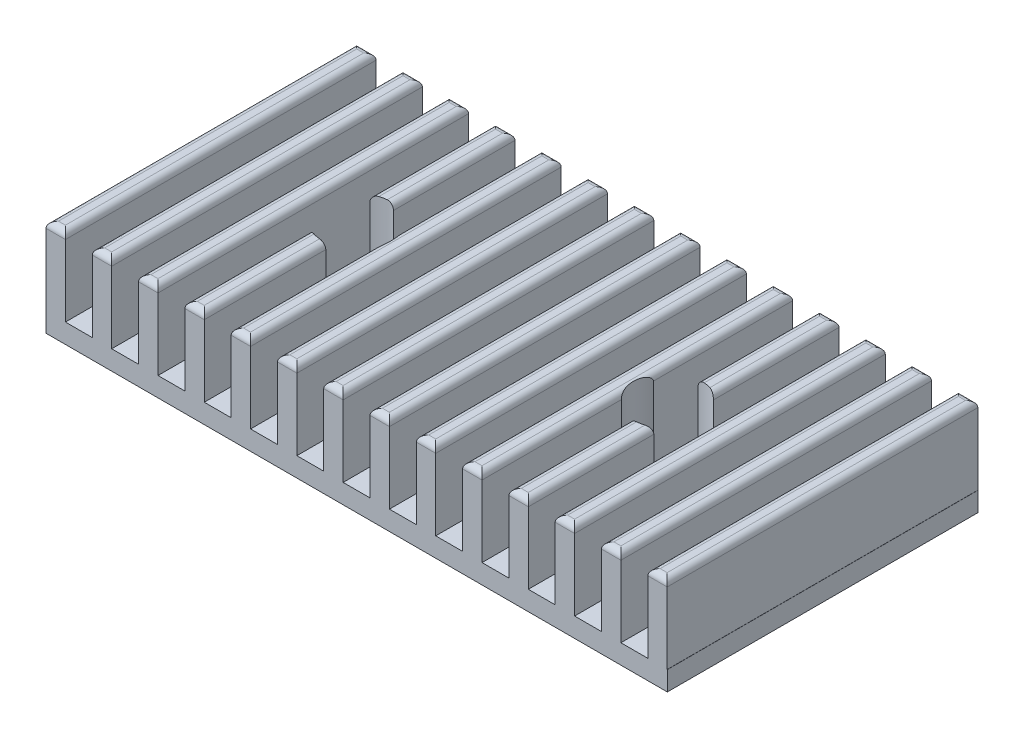
from build123d import *

# Parameters (mm, degrees)
SKETCH2_W                                      = 50.8
SKETCH2_H                                      = 25.4
BOSS_EXTRUDE1_DEPTH                            = 1.5875
SKETCH3_W                                      = 1.5875
SKETCH3_H                                      = 25.4
BOSS_EXTRUDE2_DEPTH                            = 6.35
FILLET1_R                                      = 0.508
LPATTERN1_COUNT                                = 14
LPATTERN1_PITCH                                = 3.7846
FILLET1_OF_LPATTERN1_R                         = 0.508
CBORE_FOR_4_SOCKET_HEAD_CAP_SCREW1_D           = 3.2639
CBORE_FOR_4_SOCKET_HEAD_CAP_SCREW1_CBORE_D     = 5.55752
CBORE_FOR_4_SOCKET_HEAD_CAP_SCREW1_CBORE_DEPTH = 6.35


with BuildPart() as part:
    # Sketch2 → Boss-Extrude1 (new body)
    with BuildSketch(Plane(origin=(0, 0, 0), x_dir=(1, 0, 0), z_dir=(0, 1, 0))):
        with Locations((4.112380952, -1.952517007)):
            Rectangle(SKETCH2_W, SKETCH2_H)
    extrude(amount=BOSS_EXTRUDE1_DEPTH)

    # Sketch3 → Boss-Extrude2 (add)
    with BuildSketch(Plane(origin=(0, 1.5875, 0), x_dir=(1, 0, 0), z_dir=(0, 1, 0))):
        with Locations((-20.493869048, -1.952517007)):
            Rectangle(SKETCH3_W, SKETCH3_H)
    boss_extrude2 = extrude(amount=BOSS_EXTRUDE2_DEPTH)

    # Fillet1
    fillet1_edges = [part.edges().sort_by_distance(p)[0] for p in [
        (-20.493869048, 7.9375, -10.747482993),
        (-21.287619048, 7.9375, 1.952517007),
        (-20.493869048, 7.9375, 14.652517007),
        (-19.700119048, 7.9375, 1.952517007),
    ]]
    fillet(fillet1_edges, radius=FILLET1_R)

    # LPattern1: Boss-Extrude2 ×14
    with Locations(*[(i * LPATTERN1_PITCH, 0, 0) for i in range(1, LPATTERN1_COUNT)]):
        add(boss_extrude2)

    # Fillet1 of LPattern1
    fillet1_of_lpattern1_edges = [part.edges().sort_by_distance(p)[0] for p in [
        (-16.709269048, 7.9375, -10.747482993),
        (-17.503019048, 7.9375, 1.952517007),
        (-16.709269048, 7.9375, 14.652517007),
        (-15.915519048, 7.9375, 1.952517007),
        (-12.924669048, 7.9375, -10.747482993),
        (-13.718419048, 7.9375, 1.952517007),
        (-12.924669048, 7.9375, 14.652517007),
        (-12.130919048, 7.9375, 1.952517007),
        (-9.140069048, 7.9375, -10.747482993),
        (-9.933819048, 7.9375, 1.952517007),
        (-9.140069048, 7.9375, 14.652517007),
        (-8.346319048, 7.9375, 1.952517007),
        (-5.355469048, 7.9375, -10.747482993),
        (-6.149219048, 7.9375, 1.952517007),
        (-5.355469048, 7.9375, 14.652517007),
        (-4.561719048, 7.9375, 1.952517007),
        (-1.570869048, 7.9375, -10.747482993),
        (-2.364619048, 7.9375, 1.952517007),
        (-1.570869048, 7.9375, 14.652517007),
        (-0.777119048, 7.9375, 1.952517007),
        (2.213730952, 7.9375, -10.747482993),
        (1.419980952, 7.9375, 1.952517007),
        (2.213730952, 7.9375, 14.652517007),
        (3.007480952, 7.9375, 1.952517007),
        (5.998330952, 7.9375, -10.747482993),
        (5.204580952, 7.9375, 1.952517007),
        (5.998330952, 7.9375, 14.652517007),
        (6.792080952, 7.9375, 1.952517007),
        (9.782930952, 7.9375, -10.747482993),
        (8.989180952, 7.9375, 1.952517007),
        (9.782930952, 7.9375, 14.652517007),
        (10.576680952, 7.9375, 1.952517007),
        (13.567530952, 7.9375, -10.747482993),
        (12.773780952, 7.9375, 1.952517007),
        (13.567530952, 7.9375, 14.652517007),
        (14.361280952, 7.9375, 1.952517007),
        (17.352130952, 7.9375, -10.747482993),
        (16.558380952, 7.9375, 1.952517007),
        (17.352130952, 7.9375, 14.652517007),
        (18.145880952, 7.9375, 1.952517007),
        (21.136730952, 7.9375, -10.747482993),
        (20.342980952, 7.9375, 1.952517007),
        (21.136730952, 7.9375, 14.652517007),
        (21.930480952, 7.9375, 1.952517007),
        (24.921330952, 7.9375, -10.747482993),
        (24.127580952, 7.9375, 1.952517007),
        (24.921330952, 7.9375, 14.652517007),
        (25.715080952, 7.9375, 1.952517007),
        (28.705930952, 7.9375, -10.747482993),
        (27.912180952, 7.9375, 1.952517007),
        (28.705930952, 7.9375, 14.652517007),
        (29.499680952, 7.9375, 1.952517007),
    ]]
    fillet(fillet1_of_lpattern1_edges, radius=FILLET1_OF_LPATTERN1_R)

    # CBORE for #4 Socket Head Cap Screw1 (through all)
    with Locations(Plane(origin=(-8.597783115, 7.9375, 1.952517007), x_dir=(0, 0, 1), z_dir=(0, 1, 0))):
        with Locations((0, 0), (0, 25.407628135)):
            CounterBoreHole(CBORE_FOR_4_SOCKET_HEAD_CAP_SCREW1_D / 2, CBORE_FOR_4_SOCKET_HEAD_CAP_SCREW1_CBORE_D / 2, CBORE_FOR_4_SOCKET_HEAD_CAP_SCREW1_CBORE_DEPTH)


solid = part.part
